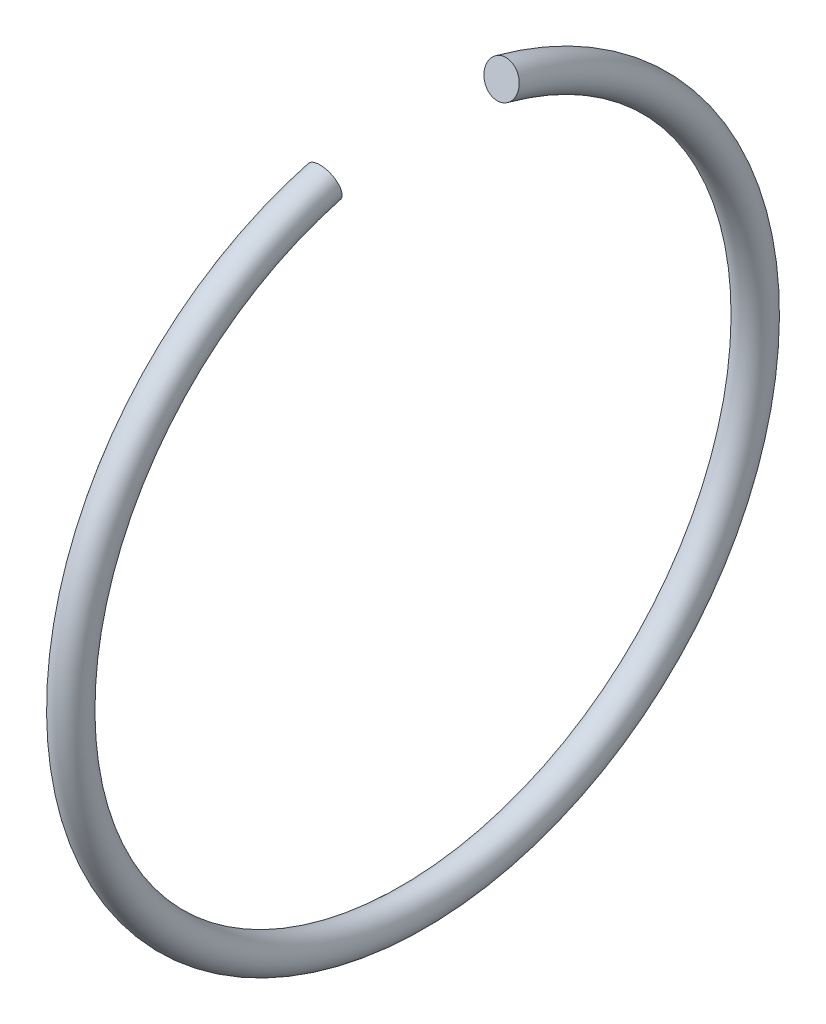
from build123d import *
from build123d.topology import SkipClean

# Parameters (mm, degrees)
SKICA1_R       = 1.25
ROTOVAT1_ANGLE = 330


with BuildPart() as part:
    # Skica1 → Rotovat1 (revolve, symmetric)
    with SkipClean():  # the faces are left unmerged after this step: merging them gives an invalid solid
        with BuildSketch(Plane.XY) as rotovat1_sk:
            with Locations((-213.8, -25)):
                Circle(SKICA1_R)
        revolve(axis=Axis((-67.482261058, 0, 0), (-1, 0, 0)), revolution_arc=ROTOVAT1_ANGLE / 2)
        revolve(rotovat1_sk.sketch, axis=Axis((-67.482261058, 0, 0), (1, 0, 0)), revolution_arc=ROTOVAT1_ANGLE / 2)


solid = part.part
